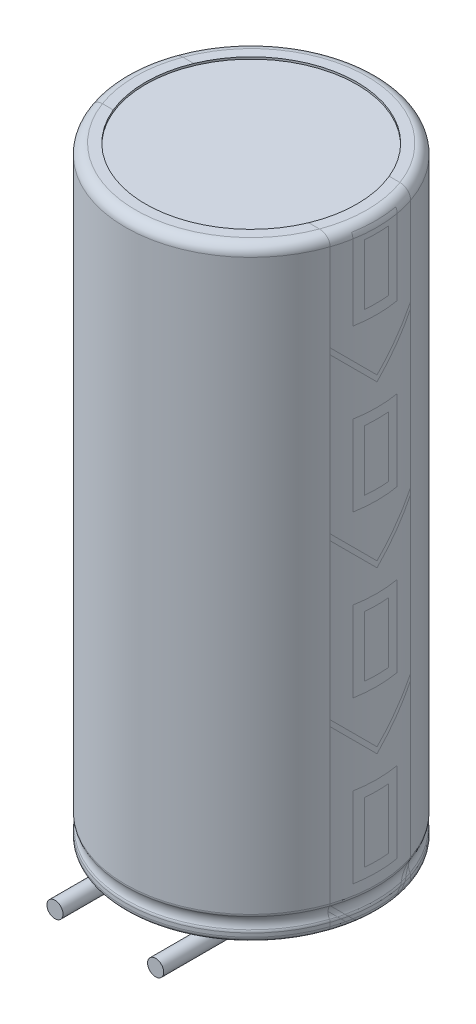
from build123d import *

# Parameters (mm, degrees)
SKETCH4_R = 0.4


with BuildPart() as part:
    # Sketch1 → Revolve1 (revolve)
    with BuildSketch(Plane.XY):
        with BuildLine():
            Line((0, 29.9), (5.25, 29.9))
            Line((5.25, 29.9), (5.25, 30))
            Line((5.25, 30), (5.75, 30))
            ThreePointArc((5.75, 30), (6.103553391, 29.853553391), (6.25, 29.5))
            Line((6.25, 29.5), (6.25, 1.231662479))
            ThreePointArc((6.25, 1.231662479), (6.242535625, 1.171028573), (6.220588235, 1.11401542))
            ThreePointArc((6.220588235, 1.11401542), (6.15, 0.831662479), (6.220588235, 0.549309538))
            ThreePointArc((6.220588235, 0.549309538), (6.242535625, 0.492296385), (6.25, 0.431662479))
            Line((6.25, 0.431662479), (6.25, 0.25))
            ThreePointArc((6.25, 0.25), (6.176776695, 0.073223305), (6, 0))
            Line((6, 0), (0, 0))
            Line((0, 0), (0, 29.9))
        make_face()
    revolve(axis=Axis((0, 0, 0), (0, 1, 0)))

    # Sweep1: sweep along a path in Sketch5
    with BuildLine(Plane(origin=(-2.5, 0, 0), x_dir=(0, 0, -1), z_dir=(1, 0, 0))) as sweep1_path:
        Line((0, 0), (0, -0.1))
        ThreePointArc((0, -0.1), (-0.146446609, -0.453553391), (-0.5, -0.6))
        Line((-0.5, -0.6), (-7.25, -0.6))
    # Sketch4 → Sweep1 (sweep)
    with BuildSketch(Plane.XZ):
        with Locations((-2.5, 0)):
            Circle(SKETCH4_R)
    sweep1 = sweep(path=sweep1_path.line)

    # Mirror1: Sweep1 across plane
    add(sweep1.mirror(Plane(origin=(0, 0, 0), x_dir=(0, 0, 1), z_dir=(1, 0, 0))))


solid = part.part
